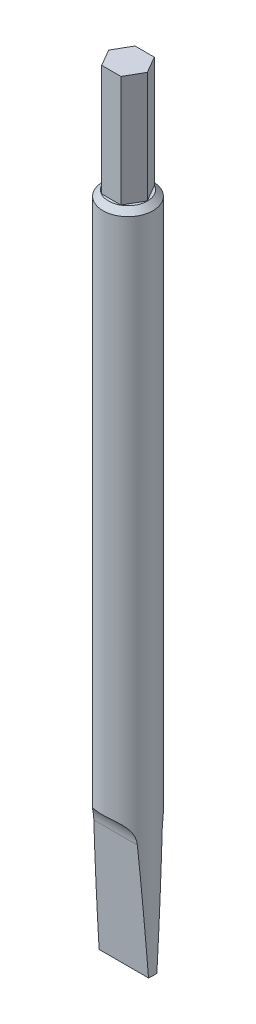
from build123d import *

# Parameters (mm, degrees)
BOSS_EXTRUDE1_DEPTH     = 20
SKETCH1_3_R             = 4.5
BOSS_EXTRUDE2_DEPTH     = 120
CUT_EXTRUDE1_DEPTH      = 121.168631514
CUT_EXTRUDE1_DEPTH_BACK = 121.168631514
CHAMFER1_SIZE           = 1


with BuildPart() as part:
    # Sketch1 → Boss-Extrude1 (new body)
    with BuildSketch(Plane(origin=(0, 0, 0), x_dir=(1, 0, 0), z_dir=(0, 1, 0))):
        Polygon((1.732050808, 3), (-1.732050808, 3), (-3.464101615, 0), (-1.732050808, -3), (1.732050808, -3), (3.464101615, 0), align=None)
    extrude(amount=BOSS_EXTRUDE1_DEPTH)

    # Sketch1_3 → Boss-Extrude2 (add)
    with BuildSketch(Plane(origin=(0, 0, 0), x_dir=(1, 0, 0), z_dir=(0, 1, 0))):
        Circle(SKETCH1_3_R)
    extrude(amount=-BOSS_EXTRUDE2_DEPTH)

    # Sketch3 → Cut-Extrude1 (cut, two sides: drawn at the far end of the back side and taken through both)
    with BuildSketch(Plane(origin=(0, 0, 0), x_dir=(0, 0, -1), z_dir=(1, 0, 0)).offset(-CUT_EXTRUDE1_DEPTH_BACK)):
        with BuildLine():
            Line((0.75, -120), (4.5, -120))
            Line((4.5, -120), (4.5, -95))
            ThreePointArc((4.5, -95), (2.910634909, -96.656515683), (2.229044758, -98.848674543))
            Line((2.229044758, -98.848674543), (0.75, -120))
        make_face()
        with BuildLine():
            Line((-4.5, -95), (-4.5, -120))
            Line((-4.5, -120), (-0.75, -120))
            Line((-0.75, -120), (-2.229044758, -98.848674543))
            ThreePointArc((-2.229044758, -98.848674543), (-2.910634909, -96.656515683), (-4.5, -95))
        make_face()
    extrude(amount=CUT_EXTRUDE1_DEPTH + CUT_EXTRUDE1_DEPTH_BACK, mode=Mode.SUBTRACT)

    # Chamfer1
    chamfer1_edges = [part.edges().sort_by_distance(p)[0] for p in [
        (-4.5, 0, 0),
    ]]
    chamfer(chamfer1_edges, length=CHAMFER1_SIZE)


solid = part.part
